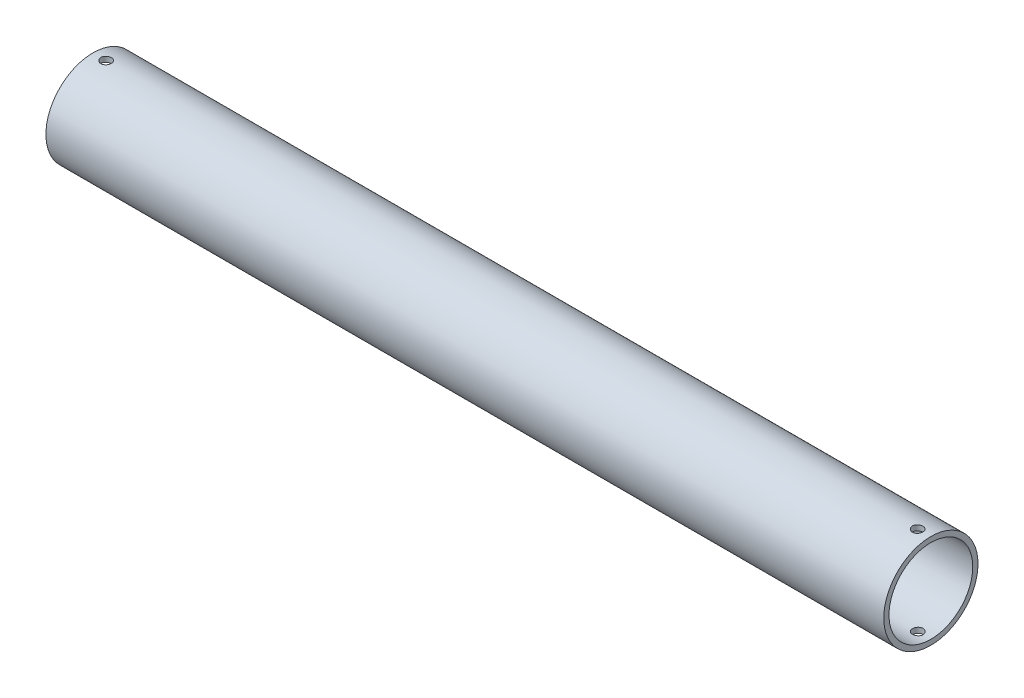
from build123d import *

# Parameters (mm, degrees)
SKETCH1_R               = 28.575
SKETCH1_R_2             = 25.4
BOSS_EXTRUDE1_DEPTH     = 508
SKETCH2_R               = 3.175
CUT_EXTRUDE1_DEPTH      = 29.575
CUT_EXTRUDE1_DEPTH_BACK = 29.575


with BuildPart() as part:
    # Sketch1 → Boss-Extrude1 (new body)
    with BuildSketch(Plane(origin=(0, 0, 0), x_dir=(0, 0, -1), z_dir=(1, 0, 0))):
        Circle(SKETCH1_R)
        Circle(SKETCH1_R_2, mode=Mode.SUBTRACT)
    extrude(amount=BOSS_EXTRUDE1_DEPTH)

    # Sketch2 → Cut-Extrude1 (cut, two sides)
    with BuildSketch(Plane(origin=(0, 0, 0), x_dir=(1, 0, 0), z_dir=(0, 1, 0))) as cut_extrude1_sk:
        with Locations((7.976402963, 0)):
            Circle(SKETCH2_R)
        with Locations((500.023597037, 0)):
            Circle(SKETCH2_R)
    extrude(amount=CUT_EXTRUDE1_DEPTH, mode=Mode.SUBTRACT)
    extrude(cut_extrude1_sk.sketch, amount=-CUT_EXTRUDE1_DEPTH_BACK, mode=Mode.SUBTRACT)


solid = part.part
